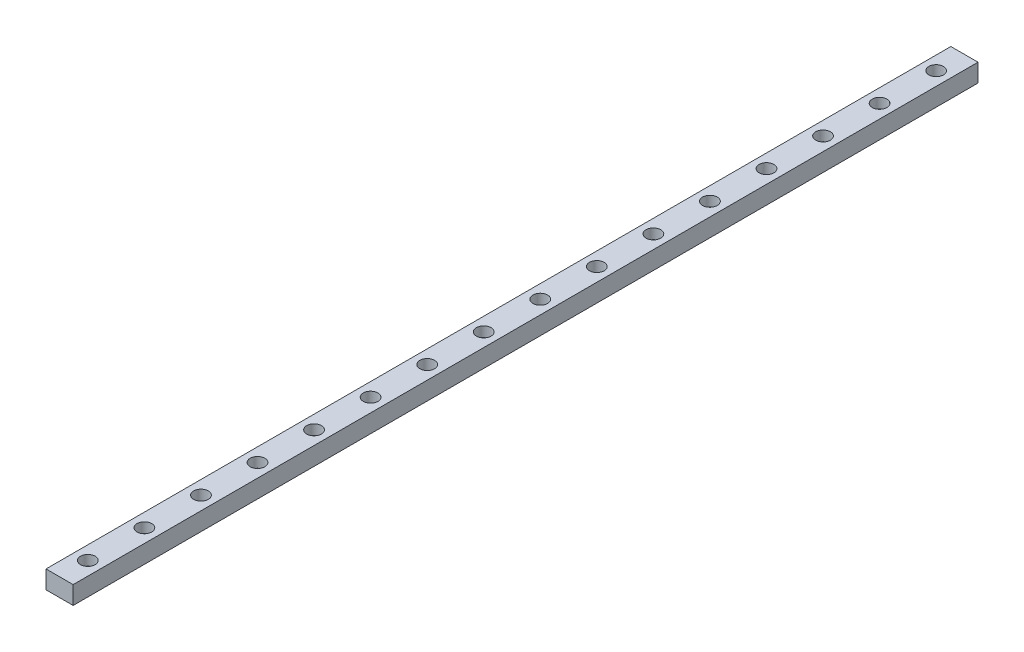
from build123d import *

# Parameters (mm, degrees)
SKETCH1_W                      = 12
SKETCH1_H                      = 8
BOSS_EXTRUDE1_DEPTH            = 400
CBORE_FOR_M3_SHCS1_D           = 3.4
CBORE_FOR_M3_SHCS1_CBORE_D     = 6.5
CBORE_FOR_M3_SHCS1_CBORE_DEPTH = 4.5
LPATTERN1_COUNT                = 16
LPATTERN1_PITCH                = 25


with BuildPart() as part:
    # Sketch1 → Boss-Extrude1 (new body)
    with BuildSketch(Plane.XY):
        with Locations((6, 4)):
            Rectangle(SKETCH1_W, SKETCH1_H)
    extrude(amount=BOSS_EXTRUDE1_DEPTH)

    # CBORE for M3 SHCS1 (through all)
    with Locations(Plane(origin=(0, 8, 0), x_dir=(1, 0, 0), z_dir=(0, 1, 0))):
        with Locations((6, -387.5)):
            cbore_for_m3_shcs1 = CounterBoreHole(CBORE_FOR_M3_SHCS1_D / 2, CBORE_FOR_M3_SHCS1_CBORE_D / 2, CBORE_FOR_M3_SHCS1_CBORE_DEPTH)

    # LPattern1: CBORE for M3 SHCS1 ×16
    with Locations(*[(0, 0, -i * LPATTERN1_PITCH) for i in range(1, LPATTERN1_COUNT)]):
        add(cbore_for_m3_shcs1, mode=Mode.SUBTRACT)


solid = part.part
